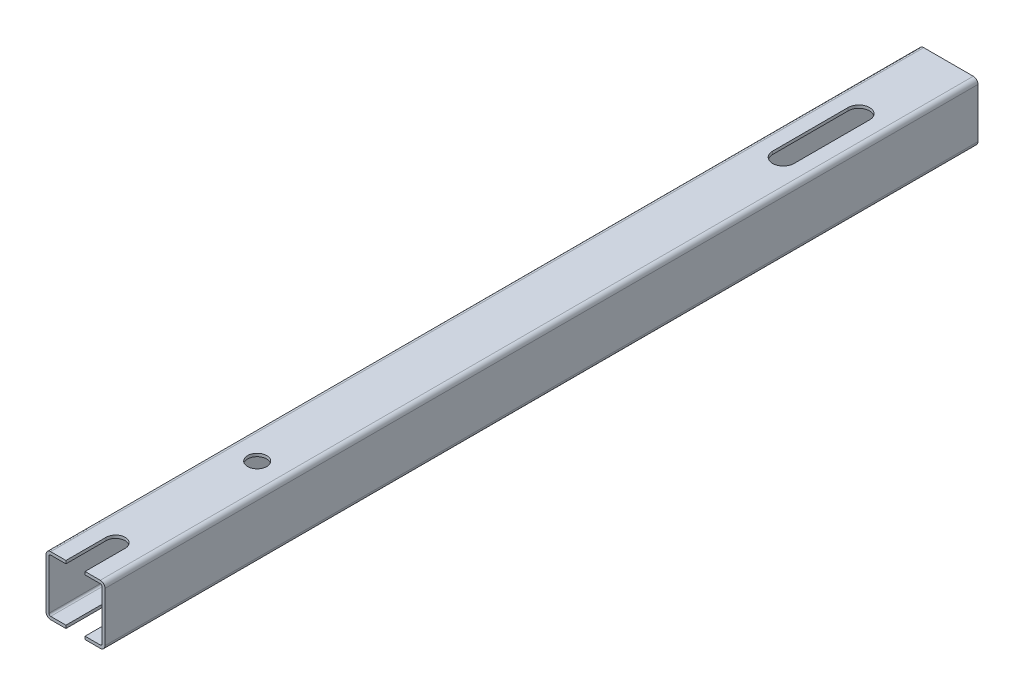
from build123d import *

# Parameters (mm, degrees)
BOSS_EXTRUDE1_DEPTH = 370
SKETCH2_R           = 4.05
CUT_EXTRUDE1_DEPTH  = 26
CUT_EXTRUDE2_REACH  = 27
CUT_EXTRUDE3_REACH  = 27
SKETCH4_R           = 6


with BuildPart() as part:
    # Sketch1 → Boss-Extrude1 (new body)
    with BuildSketch(Plane.XY):
        with BuildLine():
            Line((2, 0), (23, 0))
            ThreePointArc((23, 0), (24.414213562, 0.585786438), (25, 2))
            Line((25, 2), (25, 23))
            ThreePointArc((25, 23), (24.414213562, 24.414213562), (23, 25))
            Line((23, 25), (2, 25))
            ThreePointArc((2, 25), (0.585786438, 24.414213562), (0, 23))
            Line((0, 23), (0, 2))
            ThreePointArc((0, 2), (0.585786438, 0.585786438), (2, 0))
        make_face()
        with BuildLine():
            Line((2, 1.25), (23, 1.25))
            ThreePointArc((23, 1.25), (23.530330086, 1.469669914), (23.75, 2))
            Line((23.75, 2), (23.75, 23))
            ThreePointArc((23.75, 23), (23.530330086, 23.530330086), (23, 23.75))
            Line((23, 23.75), (2, 23.75))
            ThreePointArc((2, 23.75), (1.469669914, 23.530330086), (1.25, 23))
            Line((1.25, 23), (1.25, 2))
            ThreePointArc((1.25, 2), (1.469669914, 1.469669914), (2, 1.25))
        make_face(mode=Mode.SUBTRACT)
    extrude(amount=BOSS_EXTRUDE1_DEPTH)

    # Sketch2 → Cut-Extrude1 (cut, through all)
    with BuildSketch(Plane(origin=(0, 25, 0), x_dir=(1, 0, 0), z_dir=(0, 1, 0))):
        with Locations((12.5, -293)):
            Circle(SKETCH2_R)
        with BuildLine():
            Line((8.45, -353), (8.45, -370))
            Line((8.45, -370), (16.55, -370))
            Line((16.55, -370), (16.55, -353))
            ThreePointArc((16.55, -353), (12.5, -348.95), (8.45, -353))
        make_face()
    extrude(amount=-CUT_EXTRUDE1_DEPTH, mode=Mode.SUBTRACT)

    # Sketch3 → Cut-Extrude2 (cut, up to next)
    with BuildSketch(Plane(origin=(0, 25, 0), x_dir=(1, 0, 0), z_dir=(0, 1, 0)), mode=Mode.PRIVATE) as cut_extrude2_sk1:
        with BuildLine():
            Line((17.05, -38), (17.05, -70))
            ThreePointArc((17.05, -70), (12.5, -74.55), (7.95, -70))
            Line((7.95, -70), (7.95, -38))
            ThreePointArc((7.95, -38), (12.5, -33.45), (17.05, -38))
        make_face()
    cut_extrude2_tool1 = extrude(cut_extrude2_sk1.sketch, amount=-CUT_EXTRUDE2_REACH, mode=Mode.PRIVATE) & part.part
    add(cut_extrude2_tool1.solids().sort_by_distance((12.5, 25, 54))[0], mode=Mode.SUBTRACT)

    # Sketch4 → Cut-Extrude3 (cut, up to next)
    with BuildSketch(Plane.XZ, mode=Mode.PRIVATE) as cut_extrude3_sk1:
        with Locations((12.5, 53)):
            Circle(SKETCH4_R)
    cut_extrude3_tool1 = extrude(cut_extrude3_sk1.sketch, amount=-CUT_EXTRUDE3_REACH, mode=Mode.PRIVATE) & part.part
    add(cut_extrude3_tool1.solids().sort_by_distance((12.5, 0, 53))[0], mode=Mode.SUBTRACT)
    # Sketch4 → Cut-Extrude3 (cut, up to next)
    with BuildSketch(Plane.XZ, mode=Mode.PRIVATE) as cut_extrude3_sk2:
        with BuildLine():
            Line((7.95, 0), (7.95, 17))
            ThreePointArc((7.95, 17), (12.5, 21.55), (17.05, 17))
            Line((17.05, 17), (17.05, 0))
            Line((17.05, 0), (7.95, 0))
        make_face()
    cut_extrude3_tool2 = extrude(cut_extrude3_sk2.sketch, amount=-CUT_EXTRUDE3_REACH, mode=Mode.PRIVATE) & part.part
    add(cut_extrude3_tool2.solids().sort_by_distance((12.5, 0, 10.311845))[0], mode=Mode.SUBTRACT)


solid = part.part
